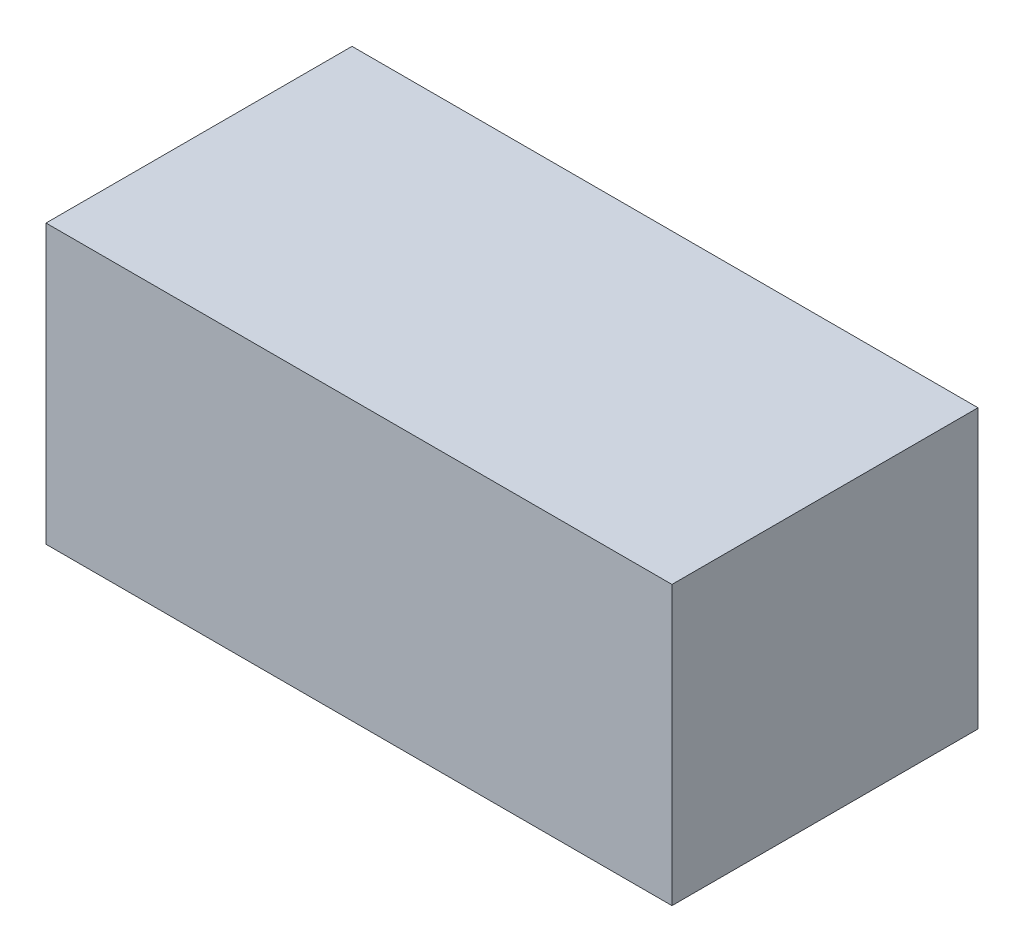
from build123d import *

# Parameters (mm, degrees)
SKETCH1_W           = 45
SKETCH1_H           = 22
BOSS_EXTRUDE1_DEPTH = 20
SKETCH2_W           = 44
SKETCH2_H           = 21
CUT_EXTRUDE1_DEPTH  = 18


with BuildPart() as part:
    # Sketch1 → Boss-Extrude1 (new body)
    with BuildSketch(Plane(origin=(0, 0, 0), x_dir=(1, 0, 0), z_dir=(0, 1, 0))):
        with Locations((-0.676075234, -1.505224482)):
            Rectangle(SKETCH1_W, SKETCH1_H)
    extrude(amount=BOSS_EXTRUDE1_DEPTH)

    # Sketch2 → Cut-Extrude1 (cut)
    with BuildSketch(Plane.XZ):
        with Locations((-0.676075234, 1.505224482)):
            Rectangle(SKETCH2_W, SKETCH2_H)
    extrude(amount=-CUT_EXTRUDE1_DEPTH, mode=Mode.SUBTRACT)


solid = part.part
